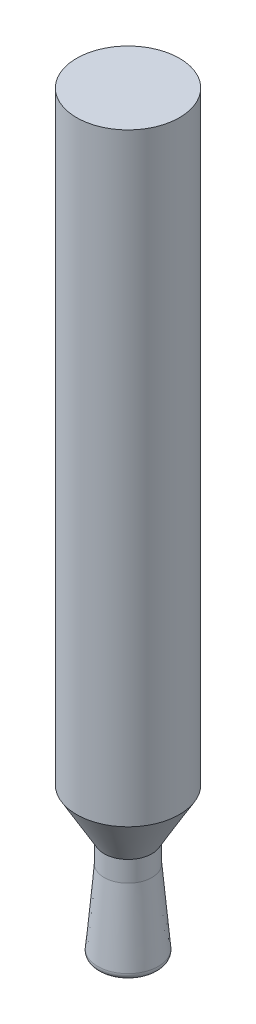
from build123d import *


with BuildPart() as part:
    # Sketch1 → Revolve3 (revolve)
    with BuildSketch(Plane.XY, mode=Mode.PRIVATE) as revolve3_sk:
        with BuildLine():
            Line((0, 0), (1.19724359, 0.09030412))
            ThreePointArc((1.19724359, 0.09030412), (1.403333579, 0.195244703), (1.473538086, 0.415601089))
            Line((1.473538086, 0.415601089), (1.159943816, 4))
            Line((1.159943816, 4), (1.159943816, 5))
            Line((1.159943816, 5), (2.5, 7.321045395))
            Line((2.5, 7.321045395), (2.5, 36.656450649))
            Line((2.5, 36.656450649), (0, 36.656450649))
            Line((0, 36.656450649), (0, 0))
        make_face()
    revolve(revolve3_sk.sketch.rotate(Axis((0, 0, 0), (0, 1, 0)), 90), axis=Axis((0, 0, 0), (0, 1, 0)))  # turned: the seam where the file's is


solid = part.part
